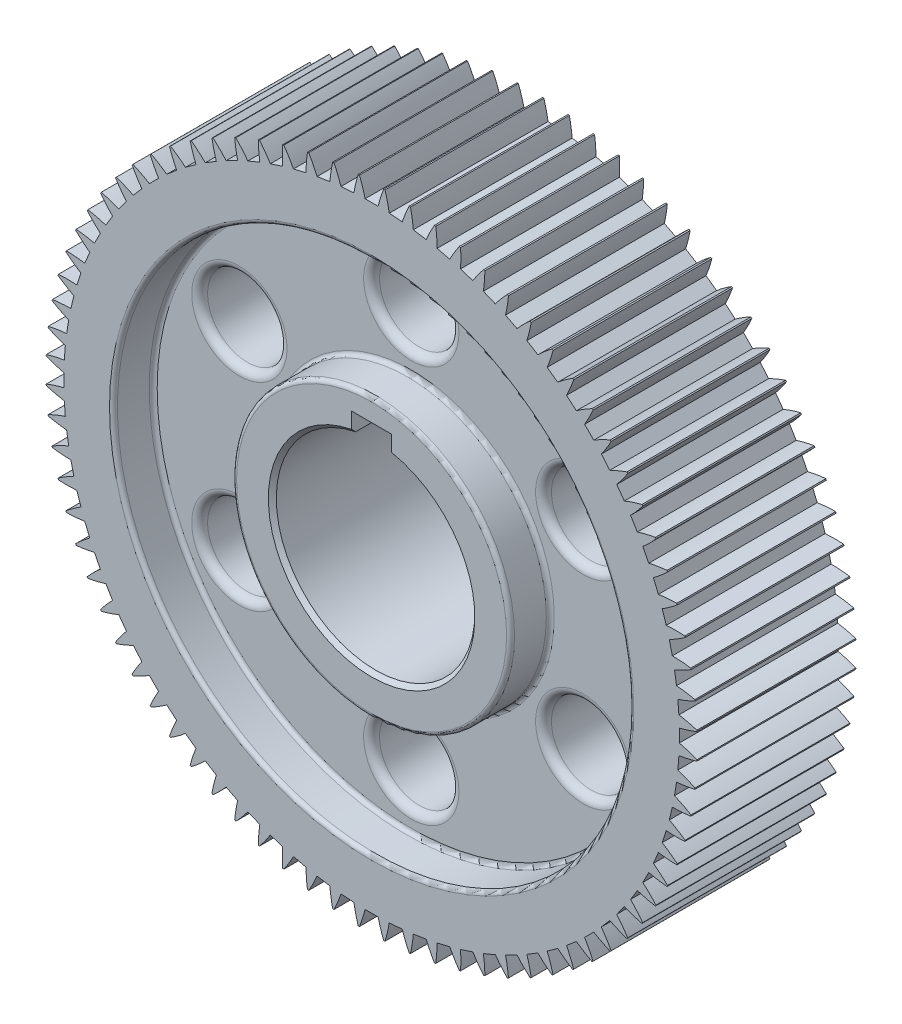
from build123d import *

# Parameters (mm, degrees)
SKETCH1_R           = 82
BOSS_EXTRUDE1_DEPTH = 40
CUT_EXTRUDE1_DEPTH  = 70
CIRPATTERN1_COUNT   = 80
CUT_EXTRUDE2_DEPTH  = 123.593963799
SKETCH5_R           = 65
SKETCH5_R_2         = 35
CUT_EXTRUDE3_DEPTH  = 10
CUT_EXTRUDE4_START  = -30
SKETCH5_2_R         = 65
SKETCH5_2_R_2       = 35
CUT_EXTRUDE4_DEPTH  = 10
SKETCH6_R           = 10
CUT_EXTRUDE5_DEPTH  = 120.704970489
CIRPATTERN2_COUNT   = 6
CHAMFER1_SIZE       = 1
FILLET1_R           = 1
FILLET2_R           = 1
FILLET3_R           = 2


with BuildPart() as part:
    # Sketch1 → Boss-Extrude1 (new body)
    with BuildSketch(Plane.XY):
        Circle(SKETCH1_R)
    extrude(amount=BOSS_EXTRUDE1_DEPTH)

    # Sketch3 → Cut-Extrude1 (cut)
    with BuildSketch(Plane.XY.offset(40)):
        with BuildLine():
            Line((3.082235405, 82), (-3.082235405, 82))
            ThreePointArc((-3.082235405, 82), (-2.280035939, 79.775379357), (-1.63574581, 77.5))
            Line((-1.63574581, 77.5), (1.63574581, 77.5))
            ThreePointArc((1.63574581, 77.5), (2.280035939, 79.775379357), (3.082235405, 82))
        make_face()
    cut_extrude1 = extrude(amount=-CUT_EXTRUDE1_DEPTH, mode=Mode.SUBTRACT)

    # CirPattern1: Cut-Extrude1 ×80 about axis
    cirpattern1_axis = Axis((0, 0, 40), (0, 0, 1))
    for i in range(1, CIRPATTERN1_COUNT):
        add(cut_extrude1.rotate(cirpattern1_axis, i * 360 / CIRPATTERN1_COUNT), mode=Mode.SUBTRACT)

    # Sketch4 → Cut-Extrude2 (cut, through all)
    with BuildSketch(Plane.XY.offset(40)):
        with BuildLine():
            Line((-5, 24.494897428), (-5, 29.494897428))
            Line((-5, 29.494897428), (5, 29.494897428))
            Line((5, 29.494897428), (5, 24.494897428))
            ThreePointArc((5, 24.494897428), (0, -25), (-5, 24.494897428))
        make_face()
    extrude(amount=-CUT_EXTRUDE2_DEPTH, mode=Mode.SUBTRACT)

    # Sketch5 → Cut-Extrude3 (cut)
    with BuildSketch(Plane.XY.offset(40)):
        Circle(SKETCH5_R)
        Circle(SKETCH5_R_2, mode=Mode.SUBTRACT)
    extrude(amount=-CUT_EXTRUDE3_DEPTH, mode=Mode.SUBTRACT)

    # Sketch5_2 → Cut-Extrude4 (cut)
    with BuildSketch(Plane.XY.offset(40).offset(CUT_EXTRUDE4_START)):
        Circle(SKETCH5_2_R)
        Circle(SKETCH5_2_R_2, mode=Mode.SUBTRACT)
    extrude(amount=-CUT_EXTRUDE4_DEPTH, mode=Mode.SUBTRACT)

    # Sketch6 → Cut-Extrude5 (cut, through all)
    with BuildSketch(Plane.XY.offset(30)):
        with Locations((0, 50)):
            Circle(SKETCH6_R)
    cut_extrude5 = extrude(amount=-CUT_EXTRUDE5_DEPTH, mode=Mode.SUBTRACT)

    # CirPattern2: Cut-Extrude5 ×6 about axis
    cirpattern2_axis = Axis((0, 0, 40), (0, 0, 1))
    for i in range(1, CIRPATTERN2_COUNT):
        add(cut_extrude5.rotate(cirpattern2_axis, i * 360 / CIRPATTERN2_COUNT), mode=Mode.SUBTRACT)

    # Chamfer1
    chamfer1_edges = [part.edges().sort_by_distance(p)[0] for p in [
        (0, -25, 40),
    ]]
    chamfer(chamfer1_edges, length=CHAMFER1_SIZE)

    # Fillet1
    fillet1_edges = [part.edges().sort_by_distance(p)[0] for p in [
        (-35, 0, 10),
        (-35, 0, 0),
        (-35, 0, 40),
        (-35, 0, 30),
    ]]
    fillet(fillet1_edges, radius=FILLET1_R)

    # Fillet2
    fillet2_edges = [part.edges().sort_by_distance(p)[0] for p in [
        (-65, 0, 40),
        (-65, 0, 30),
        (-65, 0, 10),
        (-65, 0, 0),
    ]]
    fillet(fillet2_edges, radius=FILLET2_R)

    # Fillet3
    fillet3_edges = [part.edges().sort_by_distance(p)[0] for p in [
        (38.301270189, 33.660254038, 10),
        (38.301270189, 33.660254038, 30),
        (48.301270189, -16.339745962, 10),
        (48.301270189, -16.339745962, 30),
        (10, -50, 10),
        (10, -50, 30),
        (-38.301270189, -33.660254038, 10),
        (-38.301270189, -33.660254038, 30),
        (-48.301270189, 16.339745962, 10),
        (-48.301270189, 16.339745962, 30),
        (-10, 50, 10),
        (-10, 50, 30),
    ]]
    fillet(fillet3_edges, radius=FILLET3_R)


solid = part.part
